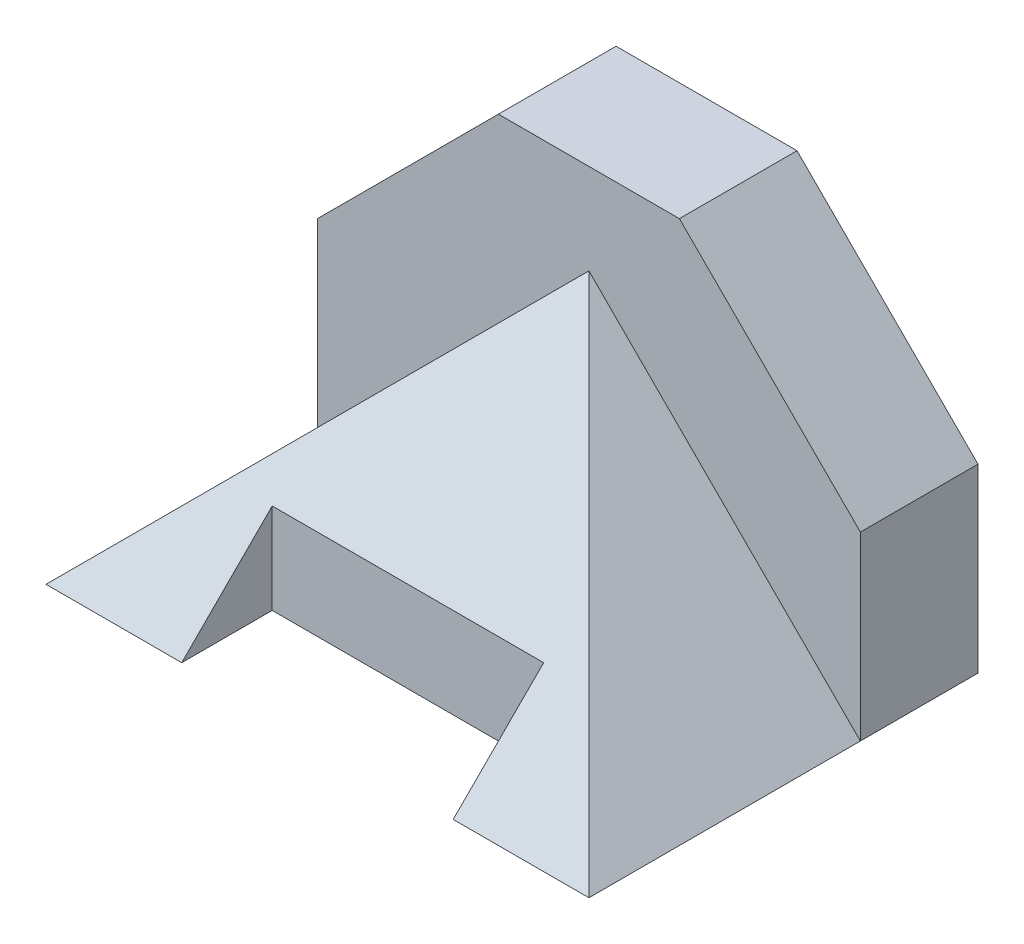
from build123d import *

# Parameters (mm, degrees)
BOSS_EXTRUDE1_DEPTH     = 33.02
BOSS_EXTRUDE2_DEPTH     = 76.2
CUT_EXTRUDE1_REACH      = 150.106
CUT_EXTRUDE2_DEPTH      = 149.106178129
CUT_EXTRUDE2_DEPTH_BACK = 149.106178129


with BuildPart() as part:
    # Sketch1 → Boss-Extrude1 (new body)
    with BuildSketch(Plane.XY):
        Polygon((-76.2, 50.8), (-76.2, 0), (0, 76.2), (0, 101.6), (-25.4, 101.6), align=None)
        Polygon((0, 101.6), (0, 76.2), (76.2, 0), (76.2, 50.8), (25.4, 101.6), align=None)
        Polygon((0, 76.2), (0, 0), (76.2, 0), align=None)
        Polygon((0, 76.2), (-76.2, 0), (0, 0), align=None)
    extrude(amount=-BOSS_EXTRUDE1_DEPTH)

    # Sketch2 → Boss-Extrude2 (add)
    with BuildSketch(Plane(origin=(0, 0, 0), x_dir=(1, 0, 0), z_dir=(0, 1, 0))):
        Polygon((-76.2, 0), (-76.2, -76.2), (-38.1, -76.2), (-38.1, -50.8), (38.1, -50.8), (38.1, -76.2), (76.2, -76.2), (76.2, 0), align=None)
    extrude(amount=BOSS_EXTRUDE2_DEPTH)

    # Sketch1_5 → Cut-Extrude1 (cut, up to next)
    with BuildSketch(Plane.XY, mode=Mode.PRIVATE) as cut_extrude1_sk1:
        Polygon((-76.2, 50.8), (-76.2, 0), (0, 76.2), (0, 101.6), (-25.4, 101.6), align=None)
    cut_extrude1_tool1 = extrude(cut_extrude1_sk1.sketch, amount=CUT_EXTRUDE1_REACH, mode=Mode.PRIVATE) & part.part
    # Sketch1_5 → Cut-Extrude1 (cut, up to next)
    with BuildSketch(Plane.XY, mode=Mode.PRIVATE) as cut_extrude1_sk2:
        Polygon((0, 101.6), (0, 76.2), (76.2, 0), (76.2, 50.8), (25.4, 101.6), align=None)
    cut_extrude1_tool2 = extrude(cut_extrude1_sk2.sketch, amount=CUT_EXTRUDE1_REACH, mode=Mode.PRIVATE) & part.part
    add(cut_extrude1_tool1.solids().sort_by_distance((-40.793939, 59.266667, 0))[0], mode=Mode.SUBTRACT)
    add(cut_extrude1_tool2.solids().sort_by_distance((40.793939, 59.266667, 0))[0], mode=Mode.SUBTRACT)


with BuildPart() as body_2:
    # of the pieces the cut leaves, the one that is kept (cut_extrude1_keep)
    add(part.part.solids().sort_by_distance((-25.4, 101.6, 0))[0])

    # Sketch6 → Cut-Extrude2 (cut, two sides)
    with BuildSketch(Plane(origin=(0, 0, 0), x_dir=(0, 0, -1), z_dir=(1, 0, 0))) as cut_extrude2_sk:
        Polygon((-76.2, 0), (0, 76.2), (-76.2, 76.2), align=None)
    extrude(amount=CUT_EXTRUDE2_DEPTH, mode=Mode.SUBTRACT)
    extrude(cut_extrude2_sk.sketch, amount=-CUT_EXTRUDE2_DEPTH_BACK, mode=Mode.SUBTRACT)


solid = body_2.part
